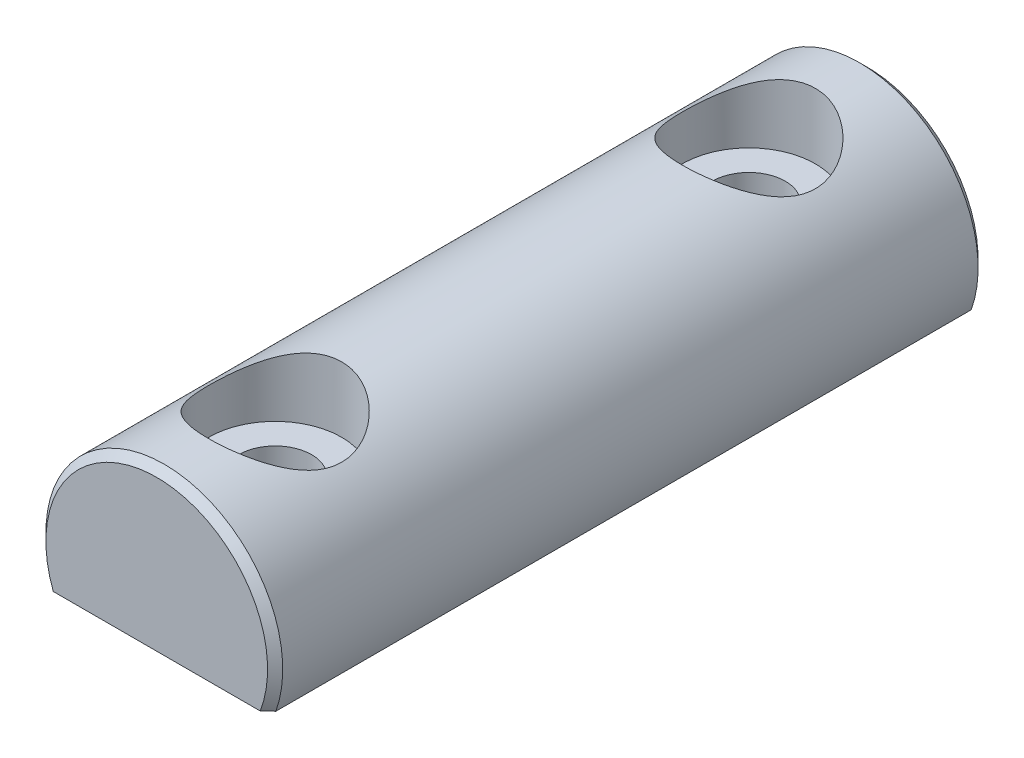
from build123d import *

# Parameters (mm, degrees)
SKETCH1_R            = 6.35
EXTRUDE1_DEPTH       = 19.05
CHAMFER1_SIZE        = 0.4064
TRUNCATED_DEPTH      = 20.05
TRUNCATED_DEPTH_BACK = 20.05
RECESSED_DEPTH       = 0.127


with BuildPart() as part:
    # Sketch1 → Extrude1 (new body, symmetric)
    with BuildSketch(Plane.XY):
        Circle(SKETCH1_R)
    extrude(amount=EXTRUDE1_DEPTH, both=True)

    # Chamfer1
    chamfer1_edges = [part.edges().sort_by_distance(p)[0] for p in [
        (-6.35, 0, -19.05),
        (-6.35, 0, 19.05),
    ]]
    chamfer(chamfer1_edges, length=CHAMFER1_SIZE)

    # Sketch2 → Truncated (cut, two sides)
    with BuildSketch(Plane.XY) as truncated_sk:
        with BuildLine():
            Line((-5.980823609, -2.1336), (5.980823609, -2.1336))
            ThreePointArc((5.980823609, -2.1336), (0, -6.35), (-5.980823609, -2.1336))
        make_face()
    extrude(amount=TRUNCATED_DEPTH, mode=Mode.SUBTRACT)
    extrude(truncated_sk.sketch, amount=-TRUNCATED_DEPTH_BACK, mode=Mode.SUBTRACT)

    # Sketch3 → Recessed (cut)
    with BuildSketch(Plane.XZ.offset(2.1336)):
        with BuildLine():
            Line((3.885323609, 17.4625), (-3.885323609, 17.4625))
            ThreePointArc((-3.885323609, 17.4625), (-4.244533854, 17.313710245), (-4.393323609, 16.9545))
            Line((-4.393323609, 16.9545), (-4.393323609, -16.9545))
            ThreePointArc((-4.393323609, -16.9545), (-4.244533854, -17.313710245), (-3.885323609, -17.4625))
            Line((-3.885323609, -17.4625), (3.885323609, -17.4625))
            ThreePointArc((3.885323609, -17.4625), (4.244533854, -17.313710245), (4.393323609, -16.9545))
            Line((4.393323609, -16.9545), (4.393323609, 16.9545))
            ThreePointArc((4.393323609, 16.9545), (4.244533854, 17.313710245), (3.885323609, 17.4625))
        make_face()
    extrude(amount=-RECESSED_DEPTH, mode=Mode.SUBTRACT)

    # Sketch5 → CtBored Hole Cut-Revolve1 (revolve, cut)
    with BuildSketch(Plane(origin=(0, 0, 0), x_dir=(0, 0, -1), z_dir=(1, 0, 0)), mode=Mode.PRIVATE) as ctbored_hole_cut_revolve1_sk:
        Polygon((14.6558, -6.35), (14.6558, 2.8448), (16.2687, 2.8448), (16.2687, 6.35), (12.7, 6.35), (12.7, -6.35), align=None)
    ctbored_hole_cut_revolve1 = revolve(ctbored_hole_cut_revolve1_sk.sketch.rotate(Axis((0, 11.226654631, -12.7), (0, -1, 0)), 180), axis=Axis((0, 11.226654631, -12.7), (0, -1, 0)), mode=Mode.SUBTRACT)  # turned: the seam where the file's is

    # CtBored Hole Mirror1: CtBored Hole Cut-Revolve1 across plane
    add(ctbored_hole_cut_revolve1.mirror(Plane.XY), mode=Mode.SUBTRACT)


solid = part.part
